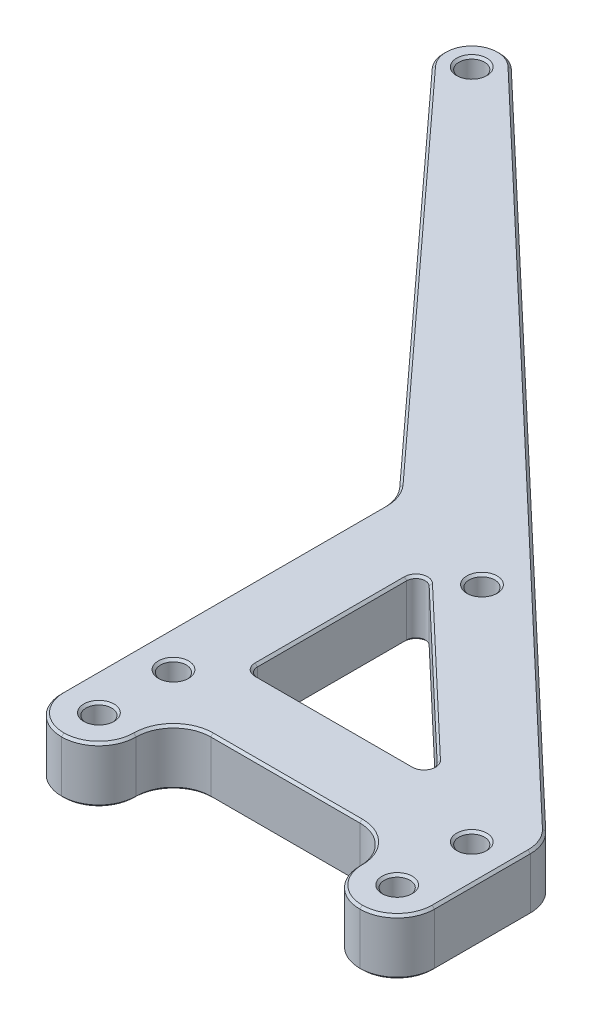
from build123d import *

# Parameters (mm, degrees)
SKETCH1_R           = 2.1828125
BOSS_EXTRUDE1_DEPTH = 9.525
CHAMFER1_SIZE       = 0.396875


with BuildPart() as part:
    # Sketch1 → Boss-Extrude1 (new body)
    with BuildSketch(Plane(origin=(0, 0, 0), x_dir=(1, 0, 0), z_dir=(0, 1, 0))):
        with BuildLine():
            Line((-6.35, 0), (-6.35, 54.968986339))
            ThreePointArc((-6.35, 54.968986339), (-6.780470884, 57.267175854), (-8.013519701, 59.253773662))
            Line((-8.013519701, 59.253773662), (-67.014860224, 123.786409508))
            ThreePointArc((-67.014860224, 123.786409508), (-66.836015353, 130.398883319), (-60.221355188, 130.454257437))
            Line((-60.221355188, 130.454257437), (55.171526417, 20.927889031))
            ThreePointArc((55.171526417, 20.927889031), (56.634453391, 18.828535178), (57.15, 16.322212447))
            Line((57.15, 16.322212447), (57.15, 0))
            ThreePointArc((57.15, 0), (55.290128061, -4.490128061), (50.8, -6.35))
            ThreePointArc((50.8, -6.35), (46.309797545, -4.490202455), (44.45, -0.000254))
            ThreePointArc((44.45, -0.000254), (42.590202455, 4.490202455), (38.100254, 6.35))
            Line((38.100254, 6.35), (12.699746, 6.35))
            ThreePointArc((12.699746, 6.35), (8.209797545, 4.490202455), (6.35, 0.000254))
            ThreePointArc((6.35, 0.000254), (4.490202455, -4.490202455), (0.000254, -6.35))
            ThreePointArc((0.000254, -6.35), (-4.490128061, -4.490128061), (-6.35, 0))
        make_face()
        Circle(SKETCH1_R, mode=Mode.SUBTRACT)
        with Locations((50.8, 12.7)):
            Circle(SKETCH1_R, mode=Mode.SUBTRACT)
        with Locations((-63.5, 127)):
            Circle(SKETCH1_R, mode=Mode.SUBTRACT)
        with Locations((0, 12.7)):
            Circle(SKETCH1_R, mode=Mode.SUBTRACT)
        with Locations((50.8, 0)):
            Circle(SKETCH1_R, mode=Mode.SUBTRACT)
        with Locations((13.727904726, 51.509581964)):
            Circle(SKETCH1_R, mode=Mode.SUBTRACT)
        with BuildLine():
            Line((35.81658762, 21.788919146), (9.030381604, 47.213328586))
            ThreePointArc((9.030381604, 47.213328586), (7.310919317, 47.520522788), (6.35, 46.06190944))
            Line((6.35, 46.06190944), (6.35, 20.6375))
            ThreePointArc((6.35, 20.6375), (6.814967985, 19.514967985), (7.9375, 19.05))
            Line((7.9375, 19.05), (34.723706016, 19.05))
            ThreePointArc((34.723706016, 19.05), (36.198160855, 20.04916406), (35.81658762, 21.788919146))
        make_face(mode=Mode.SUBTRACT)
    extrude(amount=BOSS_EXTRUDE1_DEPTH)

    # Chamfer1
    chamfer1_edges = [part.edges().sort_by_distance(p)[0] for p in [
        (56.634453391, 9.525, -18.828535178),
        (-2.524914386, 9.525, -75.691073234),
        (46.309887349, 0, 4.490292258),
        (46.309887349, 0, 4.490292258),
        (42.59038206, 0, -4.490022844),
        (42.59038206, 0, -4.490022844),
        (25.4, 0, -6.35),
        (8.209797545, 0, -4.490202455),
        (4.49038206, 0, 4.490022844),
        (4.49038206, 0, 4.490022844),
        (-4.490038256, 0, 4.490217863),
        (-66.836015353, 9.525, -130.398883319),
        (-4.490038256, 0, 4.490217863),
        (-6.35, 0, -27.484493169),
        (-6.780470884, 0, -57.267175854),
        (-37.514189963, 0, -91.520091585),
        (-66.836015353, 0, -130.398883319),
        (-2.524914386, 0, -75.691073234),
        (56.634453391, 0, -18.828535178),
        (57.15, 0, -8.161106224),
        (55.290128061, 0, 4.490128061),
        (-37.514189963, 9.525, -91.520091585),
        (-6.780470884, 9.525, -57.267175854),
        (-6.35, 9.525, -27.484493169),
        (-4.490038256, 9.525, 4.490217863),
        (-4.490038256, 9.525, 4.490217863),
        (-2.1828125, 0, 0),
        (4.49038206, 9.525, 4.490022844),
        (-2.1828125, 9.525, 0),
        (48.6171875, 0, -12.7),
        (48.6171875, 9.525, -12.7),
        (4.49038206, 9.525, 4.490022844),
        (55.290128061, 9.525, 4.490128061),
        (-65.6828125, 0, -127),
        (-65.6828125, 9.525, -127),
        (8.209797545, 9.525, -4.490202455),
        (-2.1828125, 0, -12.7),
        (-2.1828125, 9.525, -12.7),
        (25.4, 9.525, -6.35),
        (48.6171875, 0, 0),
        (48.6171875, 9.525, 0),
        (42.59038206, 9.525, -4.490022844),
        (42.59038206, 9.525, -4.490022844),
        (36.198160855, 0, -20.04916406),
        (22.423484612, 0, -34.501123866),
        (7.310919317, 0, -47.520522788),
        (46.309887349, 9.525, 4.490292258),
        (6.35, 0, -33.34970472),
        (6.814967985, 0, -19.514967985),
        (21.330603008, 0, -19.05),
        (36.198160855, 9.525, -20.04916406),
        (22.423484612, 9.525, -34.501123866),
        (7.310919317, 9.525, -47.520522788),
        (6.35, 9.525, -33.34970472),
        (6.814967985, 9.525, -19.514967985),
        (21.330603008, 9.525, -19.05),
        (46.309887349, 9.525, 4.490292258),
        (11.545092226, 0, -51.509581964),
        (11.545092226, 9.525, -51.509581964),
        (57.15, 9.525, -8.161106224),
    ]]
    chamfer(chamfer1_edges, length=CHAMFER1_SIZE)


solid = part.part
